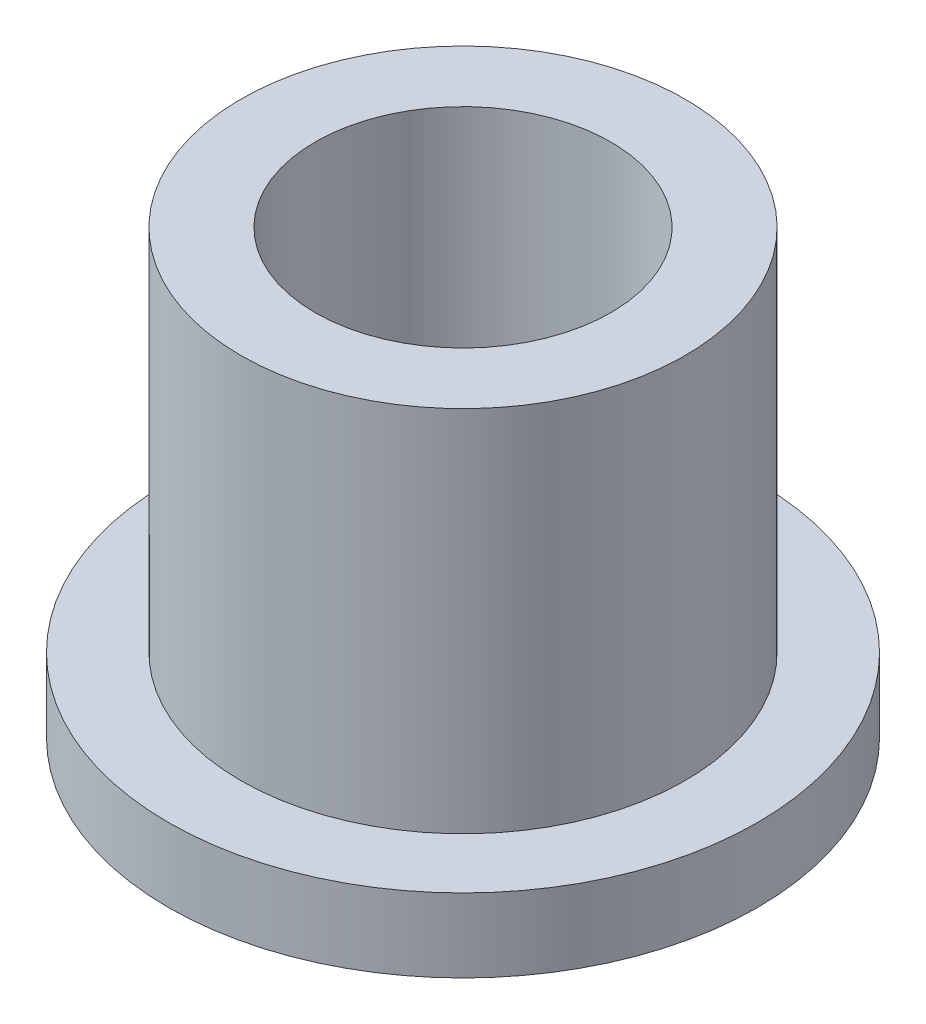
from build123d import *

# Parameters (mm, degrees)
SKETCH2_R           = 4.7879
SKETCH2_R_2         = 3.1877
BOSS_EXTRUDE1_DEPTH = 9.525
SKETCH3_R           = 6.35
SKETCH3_R_2         = 4.7879
BOSS_EXTRUDE2_DEPTH = 1.5875


with BuildPart() as part:
    # Sketch2 → Boss-Extrude1 (new body)
    with BuildSketch(Plane(origin=(0, 0, 0), x_dir=(1, 0, 0), z_dir=(0, 1, 0))):
        Circle(SKETCH2_R)
        Circle(SKETCH2_R_2, mode=Mode.SUBTRACT)
    extrude(amount=BOSS_EXTRUDE1_DEPTH)

    # Sketch3 → Boss-Extrude2 (add)
    with BuildSketch(Plane(origin=(0, 0, 0), x_dir=(1, 0, 0), z_dir=(0, 1, 0))):
        Circle(SKETCH3_R)
        Circle(SKETCH3_R_2, mode=Mode.SUBTRACT)
    extrude(amount=BOSS_EXTRUDE2_DEPTH)


solid = part.part
